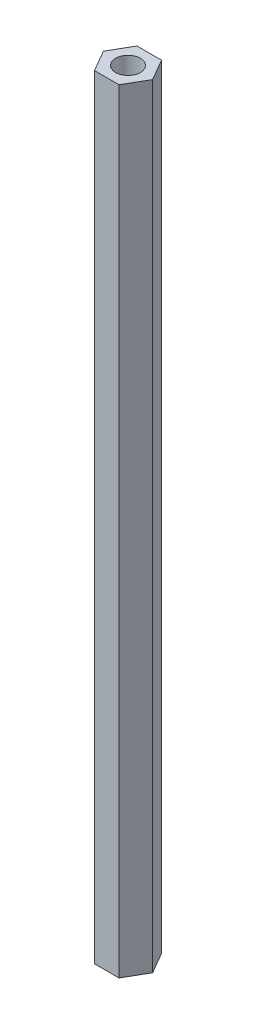
from build123d import *

# Parameters (mm, degrees)
EXTRUDE_1_DEPTH     = 100
SKETCH_2_R          = 1.6
CUT_EXTRUDE_1_DEPTH = 101


with BuildPart() as part:
    # 草图1 → 凸台-拉伸1 (new body)
    with BuildSketch(Plane(origin=(0, 0, 0), x_dir=(1, 0, 0), z_dir=(0, 1, 0))):
        Polygon((3.175426481, 0), (1.58771324, 2.75), (-1.58771324, 2.75), (-3.175426481, 0), (-1.58771324, -2.75), (1.58771324, -2.75), align=None)
    extrude(amount=EXTRUDE_1_DEPTH)

    # 草图2 → 切除-拉伸1 (cut, through all)
    with BuildSketch(Plane(origin=(0, 100, 0), x_dir=(1, 0, 0), z_dir=(0, 1, 0))):
        Circle(SKETCH_2_R)
    extrude(amount=-CUT_EXTRUDE_1_DEPTH, mode=Mode.SUBTRACT)


solid = part.part
